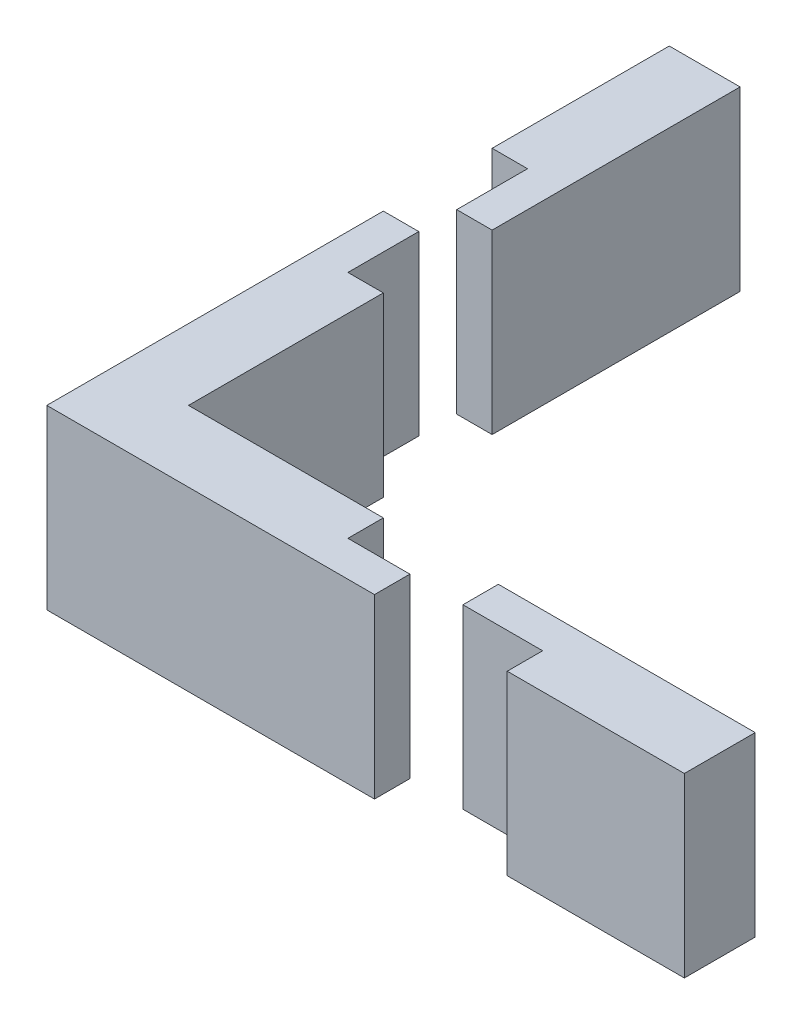
from build123d import *

# Parameters (mm, degrees)
SKETCH1_W           = 2
SKETCH1_H           = 4
SKETCH1_W_2         = 4
SKETCH1_H_2         = 15
SKETCH1_W_3         = 4.5
SKETCH1_H_3         = 2
SKETCH1_W_4         = 3.5
BOSS_EXTRUDE1_DEPTH = 10


with BuildPart() as part:
    # Sketch1 → Boss-Extrude1 (new body)
    with BuildSketch(Plane(origin=(0, 0, 0), x_dir=(1, 0, 0), z_dir=(0, 1, 0))):
        Polygon((-2, 17.642450449), (0, 17.642450449), (2, 17.642450449), (2, 27.642450449), (-2, 27.642450449), align=None)
        with Locations((1, 15.642450449)):
            Rectangle(SKETCH1_W, SKETCH1_H)
        with Locations((-1, 9.5)):
            Rectangle(SKETCH1_W, SKETCH1_H)
        Rectangle(SKETCH1_W_2, SKETCH1_H_2)
        Polygon((2, -3.5), (2, -7.5), (13, -7.5), (13, -5.5), (13, -3.5), align=None)
        with Locations((21.744860515, -4.5)):
            Rectangle(SKETCH1_W_3, SKETCH1_H_3)
        with Locations((14.75, -6.5)):
            Rectangle(SKETCH1_W_4, SKETCH1_H_3)
        Polygon((23.994860515, -3.5), (23.994860515, -5.5), (23.994860515, -7.5), (33.994860515, -7.5), (33.994860515, -3.5), align=None)
    extrude(amount=BOSS_EXTRUDE1_DEPTH)


solid = part.part
